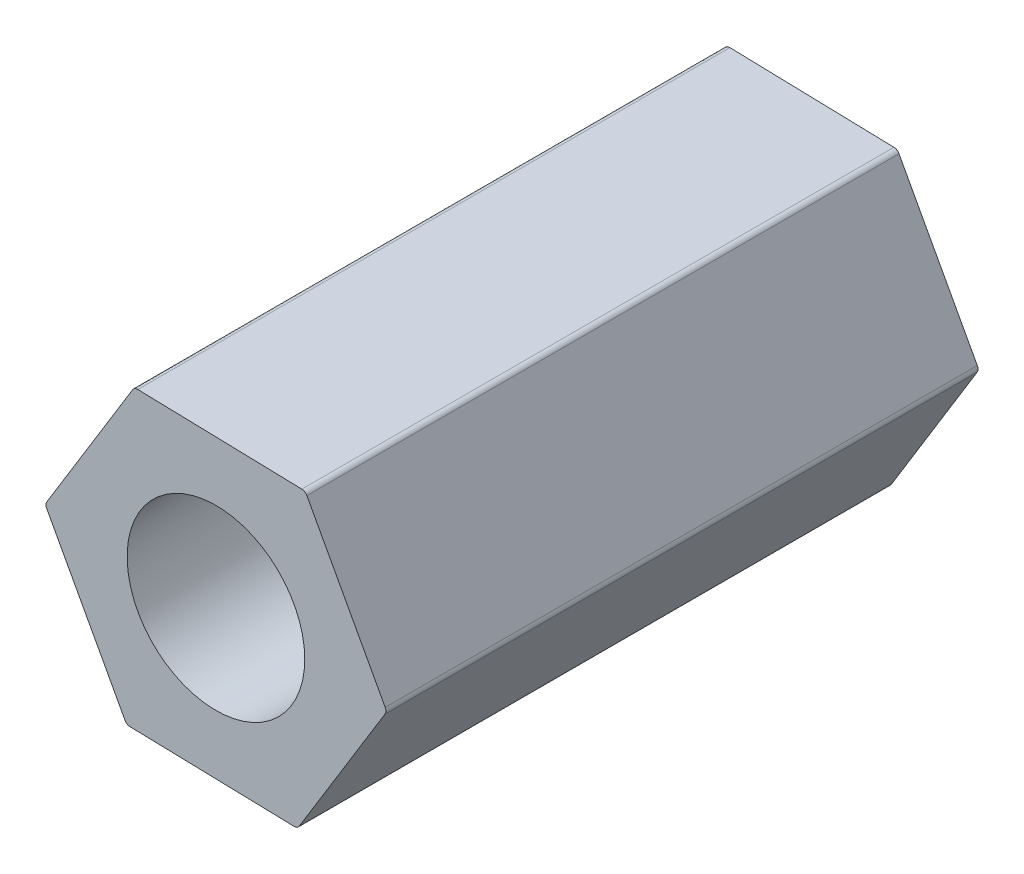
from build123d import *

# Parameters (mm, degrees)
BOSS_EXTRUDE1_DEPTH = 10
M3_TAPPED_HOLE1_D   = 3
FILLET1_R           = 0.1


with BuildPart() as part:
    # Sketch1 → Boss-Extrude1 (new body)
    with BuildSketch(Plane.XY):
        Polygon((1.508379031, 2.461326072), (-1.37738139, 2.536957595), (-2.885760421, 0.075631523), (-1.508379031, -2.461326072), (1.37738139, -2.536957595), (2.885760421, -0.075631523), align=None)
    extrude(amount=BOSS_EXTRUDE1_DEPTH)

    # M3 Tapped Hole1 (through all)
    with Locations(Plane.XY.offset(10)):
        with Locations((0, 0)):
            Hole(M3_TAPPED_HOLE1_D / 2)

    # Fillet1
    fillet1_edges = [part.edges().sort_by_distance(p)[0] for p in [
        (2.885760421, -0.075631523, 5),
        (1.37738139, -2.536957595, 5),
        (-1.508379031, -2.461326072, 5),
        (-2.885760421, 0.075631523, 5),
        (-1.37738139, 2.536957595, 5),
        (1.508379031, 2.461326072, 5),
    ]]
    fillet(fillet1_edges, radius=FILLET1_R)


solid = part.part
